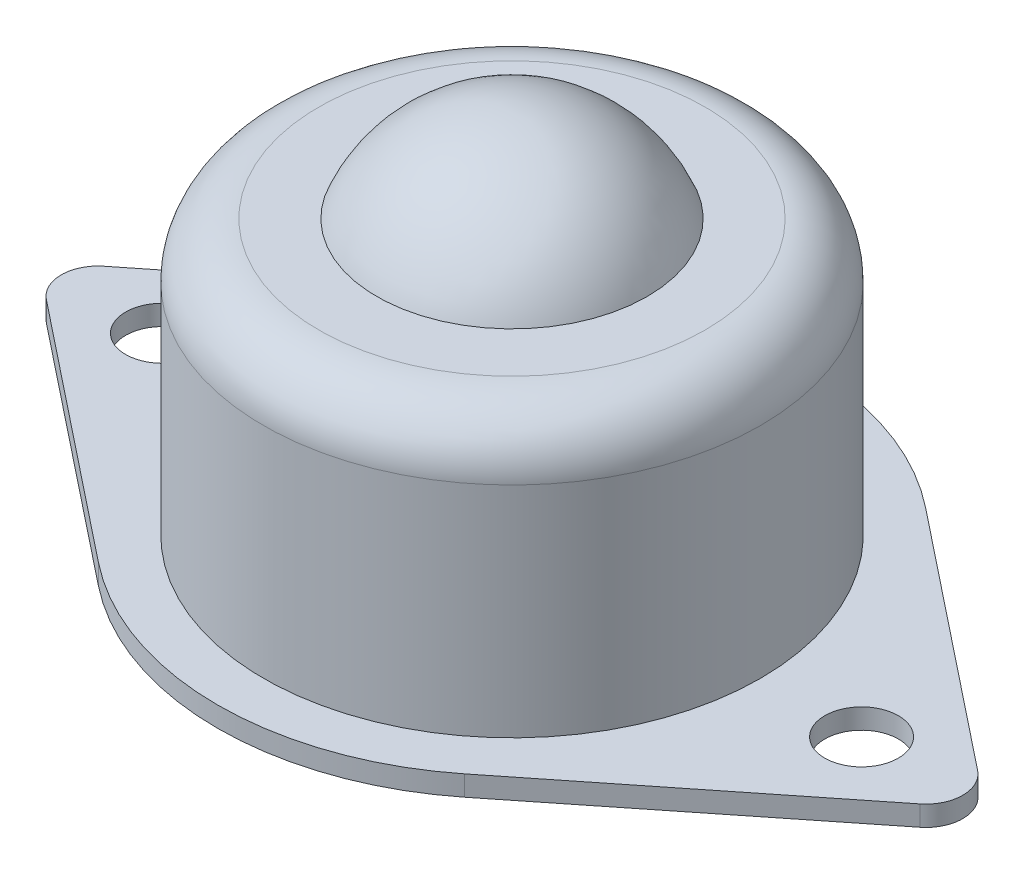
from build123d import *

# Parameters (mm, degrees)
SKETCH_1_R      = 2
EXTRUDE_1_DEPTH = 1.1


with BuildPart() as part:
    # 草图1 → 凸台-拉伸1 (new body)
    with BuildSketch(Plane(origin=(0, 0, 0), x_dir=(1, 0, 0), z_dir=(0, 1, 0))):
        with BuildLine():
            Line((-9.955555556, 12.525450634), (-23.744444444, 1.565681329))
            ThreePointArc((-23.744444444, 1.565681329), (-24.5, 0), (-23.744444444, -1.565681329))
            Line((-23.744444444, -1.565681329), (-9.955555556, -12.525450634))
            ThreePointArc((-9.955555556, -12.525450634), (0, -16), (9.955555556, -12.525450634))
            Line((9.955555556, -12.525450634), (23.744444444, -1.565681329))
            ThreePointArc((23.744444444, -1.565681329), (24.5, 0), (23.744444444, 1.565681329))
            Line((23.744444444, 1.565681329), (9.955555556, 12.525450634))
            ThreePointArc((9.955555556, 12.525450634), (0, 16), (-9.955555556, 12.525450634))
        make_face()
        with Locations((-19, 0)):
            Circle(SKETCH_1_R, mode=Mode.SUBTRACT)
        with Locations((19, 0)):
            Circle(SKETCH_1_R, mode=Mode.SUBTRACT)
    extrude(amount=EXTRUDE_1_DEPTH)

    # 草图2 → 旋转1 (revolve)
    with BuildSketch(Plane.XY):
        with BuildLine():
            Line((0, 1.1), (-13.5, 1.1))
            Line((-13.5, 1.1), (-13.5, 13))
            ThreePointArc((-13.5, 13), (-12.621320344, 15.121320344), (-10.5, 16))
            Line((-10.5, 16), (-7.348469228, 16))
            ThreePointArc((-7.348469228, 16), (-4.444097209, 19.631462317), (0, 21))
            Line((0, 21), (0, 1.1))
        make_face()
    revolve(axis=Axis((0, 1.1, 0), (0, 1, 0)))


solid = part.part
